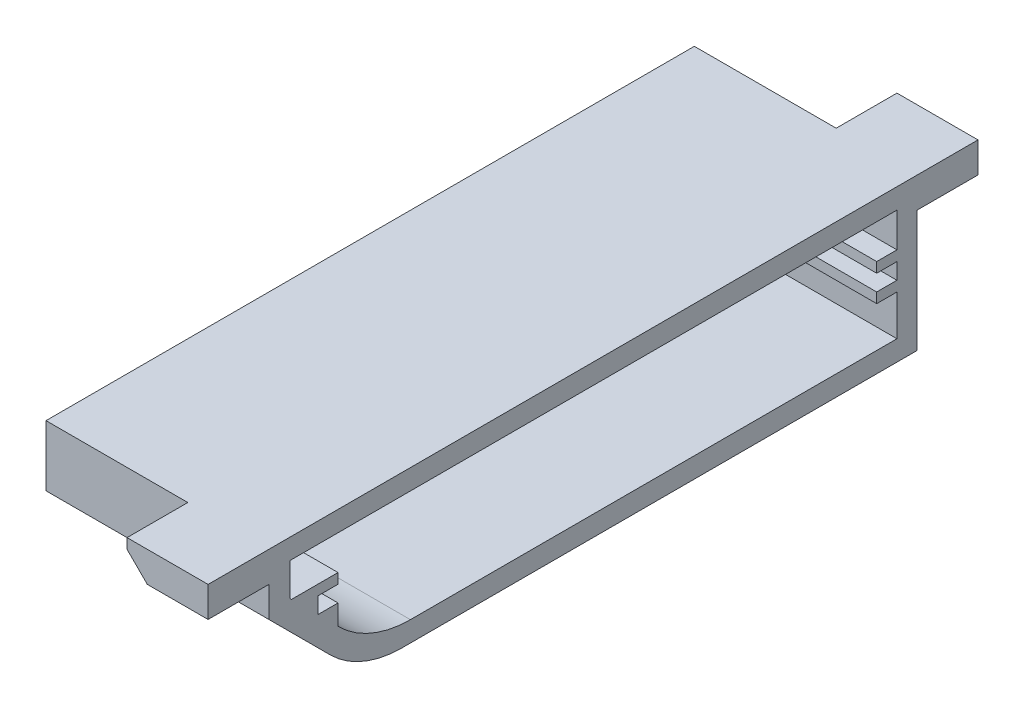
from build123d import *

# Parameters (mm, degrees)
SKETCH_1_W      = 22
SKETCH_1_H      = 15
EXTRUDE_1_DEPTH = 2
SKETCH_2_W      = 22
SKETCH_2_H      = 30
EXTRUDE_2_DEPTH = 2
EXTRUDE_3_DEPTH = 22
SKETCH_4_W      = 8
SKETCH_4_H      = 3
EXTRUDE_4_DEPTH = 6
SKETCH_5_W      = 8
SKETCH_5_H      = 3
EXTRUDE_5_DEPTH = 6
CHAMFER_1_SIZE  = 2
SKETCH_6_W      = 2
SKETCH_6_H      = 1
EXTRUDE_6_DEPTH = 22
FILLET_1_R      = 10


with BuildPart() as part:
    # 草图1 → 凸台-拉伸1 (new body)
    with BuildSketch(Plane.XY):
        with Locations((11, 7.5)):
            Rectangle(SKETCH_1_W, SKETCH_1_H)
    extrude(amount=EXTRUDE_1_DEPTH)

    # 草图2 → 凸台-拉伸2 (add)
    with BuildSketch(Plane.XZ):
        with Locations((11, 15)):
            Rectangle(SKETCH_2_W, SKETCH_2_H)
    extrude(amount=-EXTRUDE_2_DEPTH)

    # 草图3 → 凸台-拉伸3 (add)
    with BuildSketch(Plane.ZY):
        Polygon((64, 15), (0, 15), (0, 13), (61.931971091, 13), (61.931971091, 10.452580583), (61.931971091, 9.760398216), (60.906850806, 8.735277931), (55.196693161, 3.025120286), (54.171572875, 2), (53.479390508, 2), (30, 2), (30, 0), (55, 0), (64, 9), align=None)
    extrude(amount=-EXTRUDE_3_DEPTH)

    # 草图4 → 凸台-拉伸4 (add)
    with BuildSketch(Plane.XY.offset(64)):
        with Locations((18, 13.5)):
            Rectangle(SKETCH_4_W, SKETCH_4_H)
    extrude(amount=EXTRUDE_4_DEPTH)

    # 草图5 → 凸台-拉伸5 (add)
    with BuildSketch(Plane(origin=(0, 0, 0), x_dir=(-1, 0, 0), z_dir=(0, 0, -1))):
        with Locations((-18, 13.5)):
            Rectangle(SKETCH_5_W, SKETCH_5_H)
    extrude(amount=EXTRUDE_5_DEPTH)

    # 倒角1
    chamfer_1_edges = [part.edges().sort_by_distance(p)[0] for p in [
        (14, 12, 67),
        (14, 12, -3),
    ]]
    chamfer(chamfer_1_edges, length=CHAMFER_1_SIZE)

    # 草图6 → 凸台-拉伸6 (add)
    with BuildSketch(Plane.ZY):
        Polygon((57.171572875, 7), (59.171572875, 7), (59.171572875, 8.6), (57.171572875, 8.6), (57.171572875, 9.6), (61.771572875, 9.6), (61.771572875, 7.925359102), (60.513582407, 7.925359102), (60.513582407, 6.316484683), (59.171572875, 6.316484683), (59.171572875, 5), (57.171572875, 5), align=None)
        with Locations((3, 6.5)):
            Rectangle(SKETCH_6_W, SKETCH_6_H)
        with Locations((3, 9.1)):
            Rectangle(SKETCH_6_W, SKETCH_6_H)
    extrude(amount=-EXTRUDE_6_DEPTH)

    # 圆角1
    fillet_1_edges = [part.edges().sort_by_distance(p)[0] for p in [
        (11, 2, 54.171572875),
        (11, 0, 55),
    ]]
    fillet(fillet_1_edges, radius=FILLET_1_R)


solid = part.part
